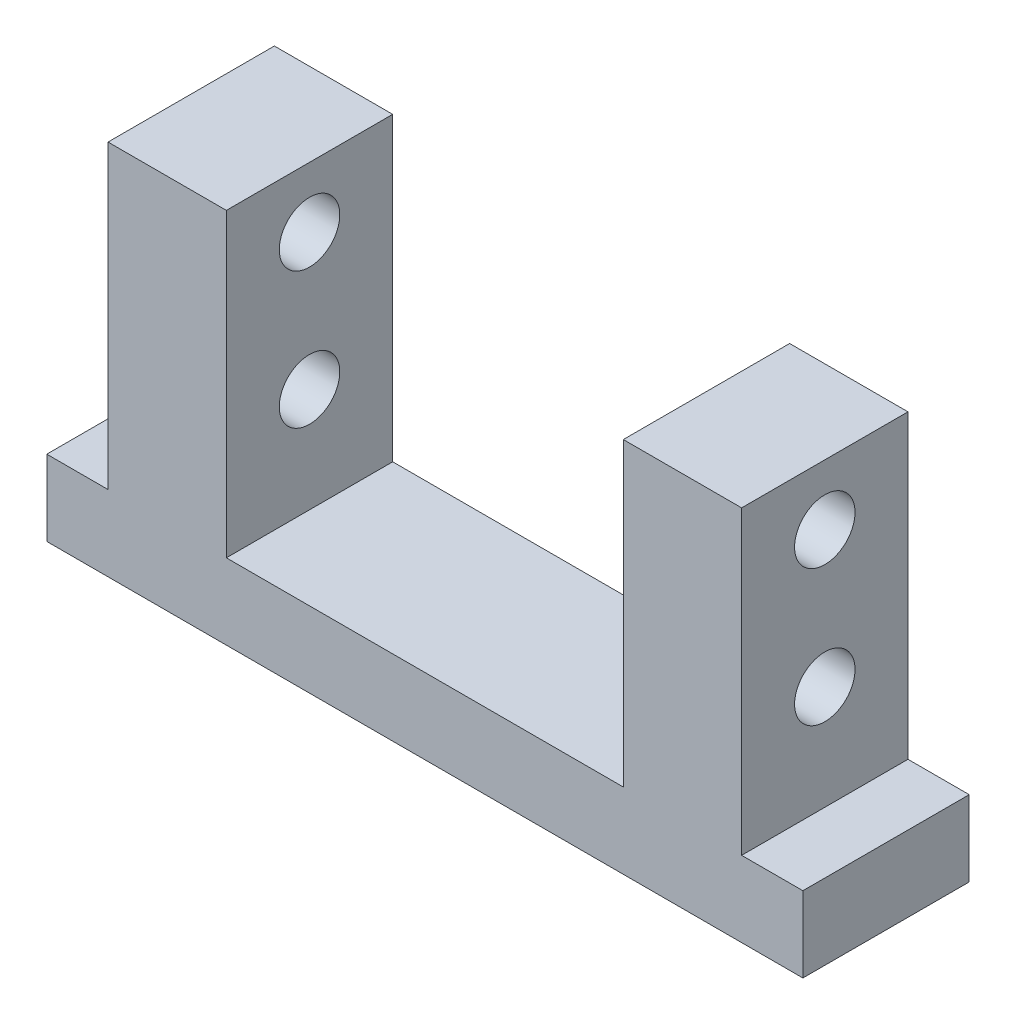
from build123d import *

# Parameters (mm, degrees)
SKETCH1_W           = 100
SKETCH1_H           = 22
BOSS_EXTRUDE1_DEPTH = 10
SKETCH2_W           = 83.8
SKETCH2_H           = 22
BOSS_EXTRUDE2_DEPTH = 39.8
SKETCH3_W           = 52.5
SKETCH3_H           = 22
CUT_EXTRUDE1_DEPTH  = 39.8
SKETCH4_R           = 4
CUT_EXTRUDE2_DEPTH  = 92.9


with BuildPart() as part:
    # Sketch1 → Boss-Extrude1 (new body)
    with BuildSketch(Plane(origin=(0, 0, 0), x_dir=(1, 0, 0), z_dir=(0, 1, 0))):
        Rectangle(SKETCH1_W, SKETCH1_H)
    extrude(amount=BOSS_EXTRUDE1_DEPTH)

    # Sketch2 → Boss-Extrude2 (add)
    with BuildSketch(Plane(origin=(0, 10, 0), x_dir=(1, 0, 0), z_dir=(0, 1, 0))):
        Rectangle(SKETCH2_W, SKETCH2_H)
    extrude(amount=BOSS_EXTRUDE2_DEPTH)

    # Sketch3 → Cut-Extrude1 (cut)
    with BuildSketch(Plane(origin=(0, 49.8, 0), x_dir=(1, 0, 0), z_dir=(0, 1, 0))):
        Rectangle(SKETCH3_W, SKETCH3_H)
    extrude(amount=-CUT_EXTRUDE1_DEPTH, mode=Mode.SUBTRACT)

    # Sketch4 → Cut-Extrude2 (cut, through all)
    with BuildSketch(Plane.ZY.offset(41.9)):
        with Locations((0, 41.8)):
            Circle(SKETCH4_R)
        with Locations((0, 23.8)):
            Circle(SKETCH4_R)
    extrude(amount=-CUT_EXTRUDE2_DEPTH, mode=Mode.SUBTRACT)


solid = part.part
